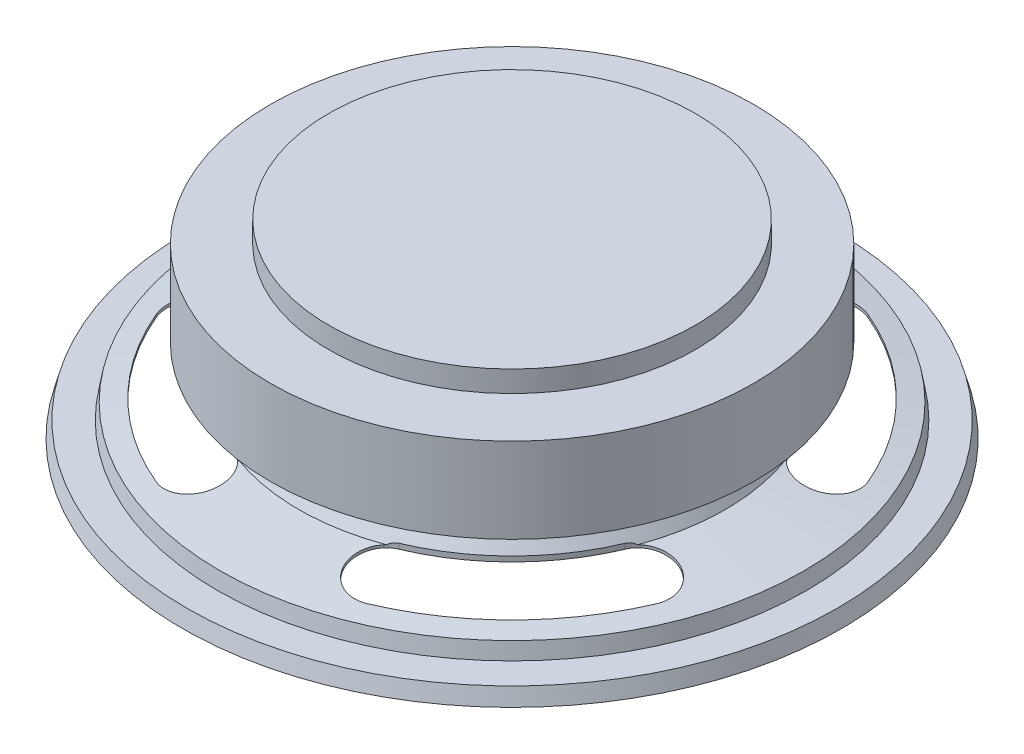
from build123d import *

# Parameters (mm, degrees)
CUT_EXTRUDE2_DEPTH       = 15.16264375
SKETCH5_W                = 4.35
SKETCH5_H                = 6.35
SKETCH6_R                = 1.5875
BOSS_EXTRUDE2_DEPTH      = 1
BOSS_EXTRUDE2_DEPTH_BACK = 9.525


with BuildPart() as part:
    # Sketch2 → Revolve-Thin1 (revolve)
    with BuildSketch(Plane.XY):
        Polygon((-24.60625, 0), (-24.293567435, 1.166947221), (-22.00484761, 1.166947221), (-21.79908333, 2.333894442), (-15.936399675, 3.36764375), (-15.203164833, 4.63764375), (-13.6921875, 4.63764375), (-13.6921875, 14.16264375), (0, 14.16264375), (0, 13.96420625), (-13.49375, 13.96420625), (-13.49375, 4.43920625), (-15.088596889, 4.43920625), (-15.810814222, 3.188289135), (-21.62778851, 2.162599622), (-21.838338777, 0.968509721), (-24.141300985, 0.968509721), (-24.414574094, -0.051359404), align=None)
    revolve(axis=Axis((0, 0, 0), (0, 1, 0)))

    # Sketch4 → Cut-Extrude2 (cut, through all)
    with BuildSketch(Plane(origin=(0, 0, 0), x_dir=(1, 0, 0), z_dir=(0, 1, 0))):
        with BuildLine():
            ThreePointArc((-18.702022535, -7.864281481), (-14.345950127, -14.345950127), (-7.864281481, -18.702022535))
            ThreePointArc((-7.864281481, -18.702022535), (-4.937265584, -17.507944491), (-6.131343629, -14.580928594))
            ThreePointArc((-6.131343629, -14.580928594), (-11.184740796, -11.184740796), (-14.580928594, -6.131343629))
            ThreePointArc((-14.580928594, -6.131343629), (-17.507944491, -4.937265584), (-18.702022535, -7.864281481))
        make_face()
        with BuildLine():
            ThreePointArc((-7.864281481, 18.702022535), (-14.345950127, 14.345950127), (-18.702022535, 7.864281481))
            ThreePointArc((-18.702022535, 7.864281481), (-17.507944491, 4.937265584), (-14.580928594, 6.131343629))
            ThreePointArc((-14.580928594, 6.131343629), (-11.184740796, 11.184740796), (-6.131343629, 14.580928594))
            ThreePointArc((-6.131343629, 14.580928594), (-4.937265584, 17.507944491), (-7.864281481, 18.702022535))
        make_face()
        with BuildLine():
            ThreePointArc((18.702022535, 7.864281481), (14.345950127, 14.345950127), (7.864281481, 18.702022535))
            ThreePointArc((7.864281481, 18.702022535), (4.937265584, 17.507944491), (6.131343629, 14.580928594))
            ThreePointArc((6.131343629, 14.580928594), (11.184740796, 11.184740796), (14.580928594, 6.131343629))
            ThreePointArc((14.580928594, 6.131343629), (17.507944491, 4.937265584), (18.702022535, 7.864281481))
        make_face()
        with BuildLine():
            ThreePointArc((7.864281481, -18.702022535), (14.345950127, -14.345950127), (18.702022535, -7.864281481))
            ThreePointArc((18.702022535, -7.864281481), (17.507944491, -4.937265584), (14.580928594, -6.131343629))
            ThreePointArc((14.580928594, -6.131343629), (11.184740796, -11.184740796), (6.131343629, -14.580928594))
            ThreePointArc((6.131343629, -14.580928594), (4.937265584, -17.507944491), (7.864281481, -18.702022535))
        make_face()
    extrude(amount=CUT_EXTRUDE2_DEPTH, mode=Mode.SUBTRACT)

    # Sketch5 → Revolve1 (revolve)
    with BuildSketch(Plane.XY):
        with Locations((-15.8671875, 9.40014375)):
            Rectangle(SKETCH5_W, SKETCH5_H)
    revolve(axis=Axis((0, 0, 0), (0, 1, 0)))

    # Sketch6 → Boss-Extrude2 (add, two sides)
    with BuildSketch(Plane.XZ.offset(-4.43920625)) as boss_extrude2_sk:
        Circle(SKETCH6_R)
    extrude(amount=BOSS_EXTRUDE2_DEPTH)
    extrude(boss_extrude2_sk.sketch, amount=-BOSS_EXTRUDE2_DEPTH_BACK)


solid = part.part
